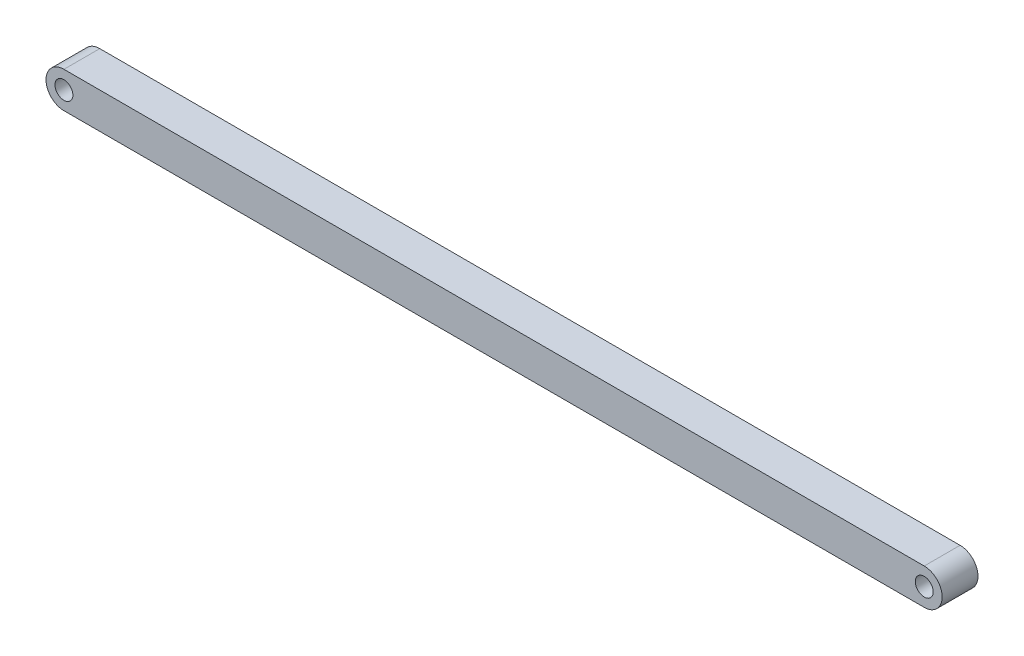
from build123d import *

# Parameters (mm, degrees)
BOSS_EXTRUDE1_DEPTH = 12.7
SKETCH2_R           = 6.35
CUT_EXTRUDE1_DEPTH  = 26.4


with BuildPart() as part:
    # Sketch1 → Boss-Extrude1 (new body, symmetric)
    with BuildSketch(Plane.XY):
        with BuildLine():
            Line((-304.8, 12.7), (304.8, 12.7))
            ThreePointArc((304.8, 12.7), (317.5, 0), (304.8, -12.7))
            Line((304.8, -12.7), (-304.8, -12.7))
            ThreePointArc((-304.8, -12.7), (-317.5, 0), (-304.8, 12.7))
        make_face()
    extrude(amount=BOSS_EXTRUDE1_DEPTH, both=True)

    # Sketch2 → Cut-Extrude1 (cut, through all)
    with BuildSketch(Plane.XY.offset(12.7)):
        with Locations((-304.8, 0)):
            Circle(SKETCH2_R)
        with Locations((304.8, 0)):
            Circle(SKETCH2_R)
    extrude(amount=-CUT_EXTRUDE1_DEPTH, mode=Mode.SUBTRACT)


solid = part.part
